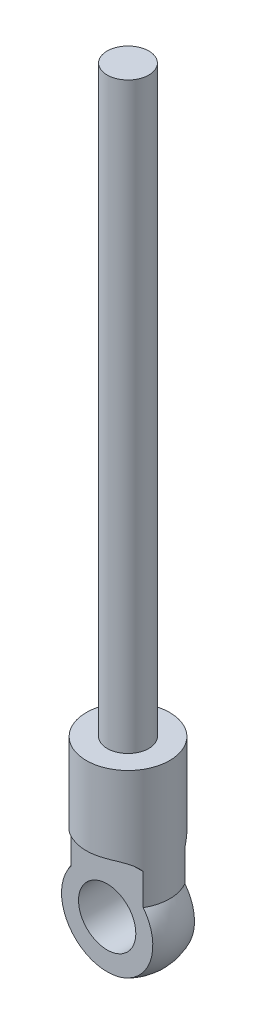
from build123d import *

# Parameters (mm, degrees)
CUT_EXTRUDE1_DEPTH      = 5.816666667
CUT_EXTRUDE1_DEPTH_BACK = 10
SKETCH3_R               = 2.75
CUT_EXTRUDE2_DEPTH      = 3.0000001
CUT_EXTRUDE2_DEPTH_BACK = 7.0000001


with BuildPart() as part:
    # Sketch1 → Revolve1 (revolve)
    with BuildSketch(Plane.XY):
        with BuildLine():
            Line((0, 0), (0, 56))
            Line((0, 56), (-2, 56))
            Line((-2, 56), (-2, 0))
            Line((-2, 0), (-4, 0))
            Line((-4, 0), (-4, -11.5))
            ThreePointArc((-4, -11.5), (-4.25, -16.45), (0, -19))
            Line((0, -19), (0, 0))
        make_face()
    revolve(axis=Axis((0, 0, 0), (0, 1, 0)))

    # Sketch2 → Cut-Extrude1 (cut, two sides)
    with BuildSketch(Plane(origin=(0, 0, 0), x_dir=(0, 0, -1), z_dir=(1, 0, 0))) as cut_extrude1_sk:
        with BuildLine():
            ThreePointArc((-2, -8.5), (-2.881966011, -7.763932023), (-4, -7.5))
            Line((-4, -7.5), (-4, -8.077978136))
            ThreePointArc((-4, -8.077978136), (-6.041123222, -13.901532194), (-2, -18.56514549))
            Line((-2, -18.56514549), (-2, -11.5))
            Line((-2, -11.5), (-2, -8.5))
        make_face()
        with BuildLine():
            Line((4, -8.077978136), (4, -7.5))
            ThreePointArc((4, -7.5), (2.881966011, -7.763932023), (2, -8.5))
            Line((2, -8.5), (2, -11.5))
            Line((2, -11.5), (2, -18.56514549))
            ThreePointArc((2, -18.56514549), (6.041123222, -13.901532194), (4, -8.077978136))
        make_face()
    extrude(amount=CUT_EXTRUDE1_DEPTH, mode=Mode.SUBTRACT)
    extrude(cut_extrude1_sk.sketch, amount=-CUT_EXTRUDE1_DEPTH_BACK, mode=Mode.SUBTRACT)

    # Sketch3 → Cut-Extrude2 (cut, two sides)
    with BuildSketch(Plane.XY.offset(2)) as cut_extrude2_sk:
        with Locations((0, -14)):
            Circle(SKETCH3_R)
    extrude(amount=CUT_EXTRUDE2_DEPTH, mode=Mode.SUBTRACT)
    extrude(cut_extrude2_sk.sketch, amount=-CUT_EXTRUDE2_DEPTH_BACK, mode=Mode.SUBTRACT)


solid = part.part
